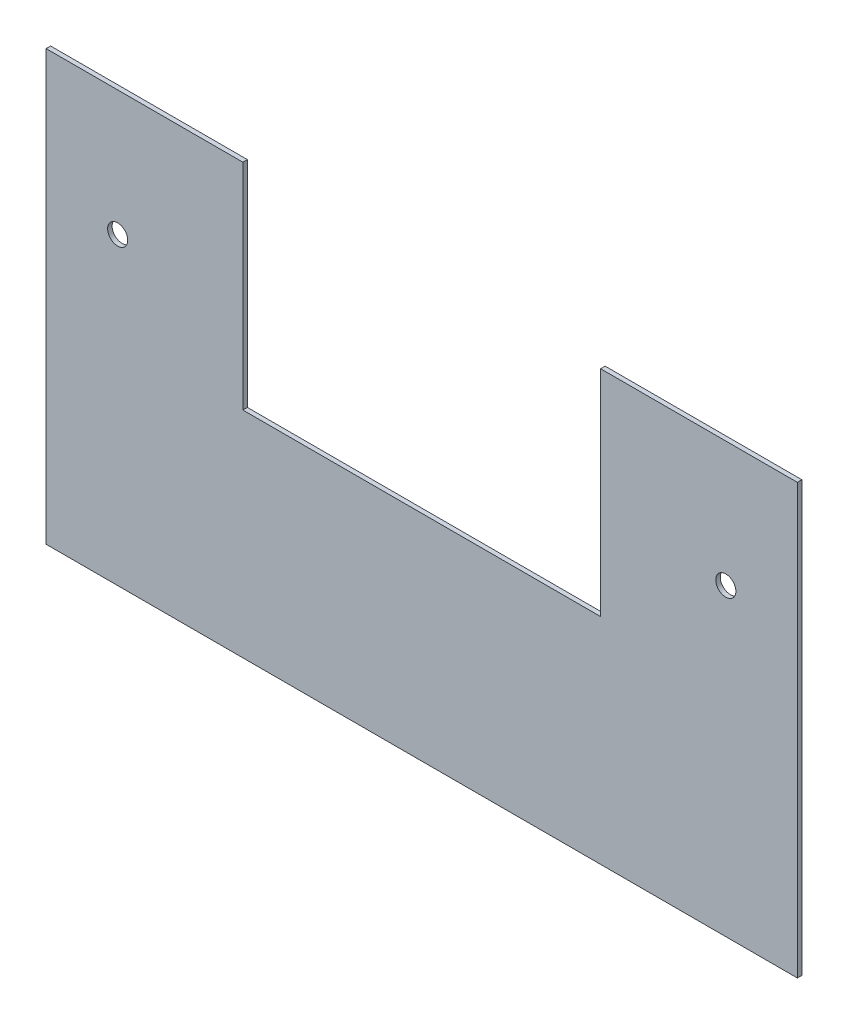
from build123d import *

# Parameters (mm, degrees)
BOSS_EXTRUDE1_DEPTH     = 1.6002
F_1_4_CLEARANCE_HOLE1_D = 7.14248


with BuildPart() as part:
    # Sketch1 → Boss-Extrude1 (new body)
    with BuildSketch(Plane.XY):
        Polygon((63.5, 76.2), (133.35, 76.2), (133.35, -76.2), (-133.35, -76.2), (-133.35, 76.2), (-63.5, 76.2), (-63.5, 0), (63.5, 0), align=None)
    extrude(amount=BOSS_EXTRUDE1_DEPTH)

    # 1/4 Clearance Hole1 (through all)
    with Locations(Plane.XY.offset(1.6002)):
        with Locations((-107.95, 31.75), (107.95, 31.75)):
            Hole(F_1_4_CLEARANCE_HOLE1_D / 2)


solid = part.part
